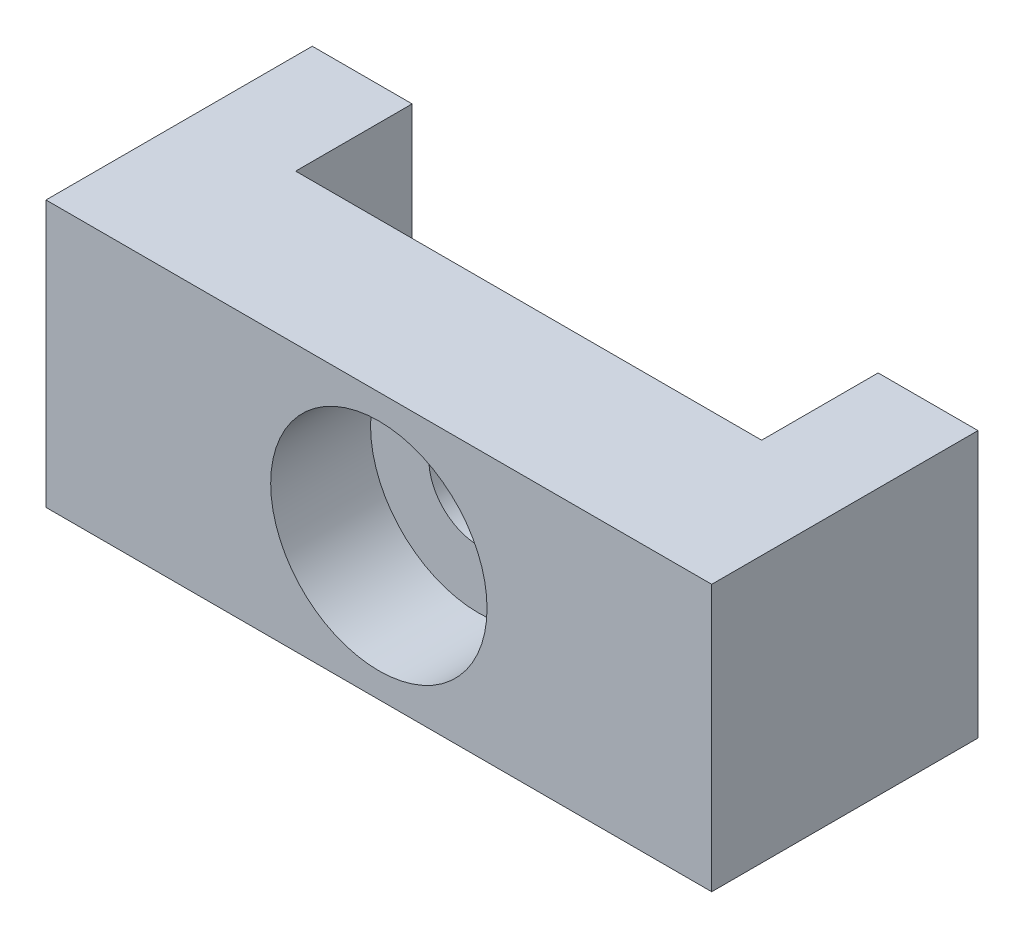
from build123d import *

# Parameters (mm, degrees)
SKETCH1_W                               = 20
SKETCH1_H                               = 8
EXTRUDE1_DEPTH                          = 8
SKETCH2_W                               = 14
SKETCH2_H                               = 8
EXTRUDE2_DEPTH                          = 3.5
CBORE_FOR_M5_HEX_HEAD_BOLT1_D           = 3
CBORE_FOR_M5_HEX_HEAD_BOLT1_CBORE_D     = 6.5
CBORE_FOR_M5_HEX_HEAD_BOLT1_CBORE_DEPTH = 3


with BuildPart() as part:
    # Sketch1 → Extrude1 (new body)
    with BuildSketch(Plane.XY):
        Rectangle(SKETCH1_W, SKETCH1_H)
    extrude(amount=-EXTRUDE1_DEPTH)

    # Sketch2 → Extrude2 (cut)
    with BuildSketch(Plane(origin=(0, 0, -8), x_dir=(-1, 0, 0), z_dir=(0, 0, -1))):
        Rectangle(SKETCH2_W, SKETCH2_H)
    extrude(amount=-EXTRUDE2_DEPTH, mode=Mode.SUBTRACT)

    # CBORE for M5 Hex Head Bolt1 (through all)
    with Locations(Plane.XY):
        with Locations((0, 0)):
            CounterBoreHole(CBORE_FOR_M5_HEX_HEAD_BOLT1_D / 2, CBORE_FOR_M5_HEX_HEAD_BOLT1_CBORE_D / 2, CBORE_FOR_M5_HEX_HEAD_BOLT1_CBORE_DEPTH)


solid = part.part
